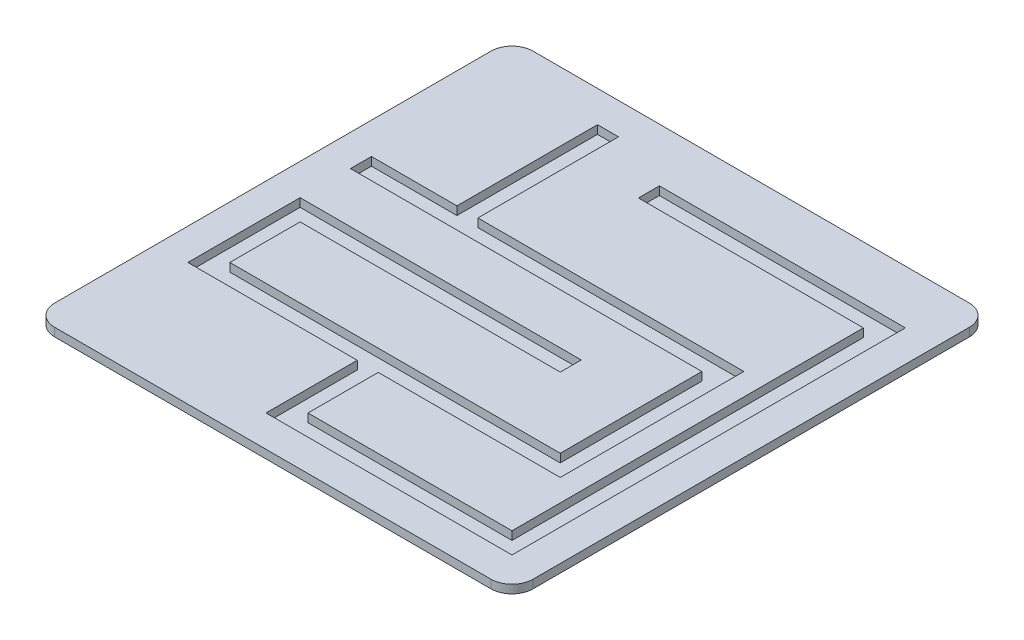
from build123d import *

# Parameters (mm, degrees)
BOSS_EXTRUDE1_DEPTH = 4
CUT_EXTRUDE3_DEPTH  = 12
BOSS_EXTRUDE6_DEPTH = 10


with BuildPart() as part:
    # Sketch1 → Boss-Extrude1 (new body)
    with BuildSketch(Plane(origin=(0, 0, 0), x_dir=(1, 0, 0), z_dir=(0, 1, 0))):
        with BuildLine():
            Line((-104, -114), (104, -114))
            ThreePointArc((104, -114), (111.071067812, -111.071067812), (114, -104))
            Line((114, -104), (114, 104))
            ThreePointArc((114, 104), (111.071067812, 111.071067812), (104, 114))
            Line((104, 114), (-104, 114))
            ThreePointArc((-104, 114), (-111.071067812, 111.071067812), (-114, 104))
            Line((-114, 104), (-114, -104))
            ThreePointArc((-114, -104), (-111.071067812, -111.071067812), (-104, -114))
        make_face()
    extrude(amount=BOSS_EXTRUDE1_DEPTH)

    # Sketch4 → Cut-Extrude3 (cut)
    with BuildSketch(Plane(origin=(0, 0, 0), x_dir=(1, 0, 0), z_dir=(0, 1, 0))):
        Polygon((-58.25, 99), (-58.25, 32), (-99, 32), (-99, 22), (68.5, 22), (68.5, -45.5), (-89, -45.5), (-89, -12), (35, -12), (35, -2), (-99, -2), (-99, -55.5), (-18.25, -55.5), (-18.25, -99), (99, -99), (99, 88.5), (-18.25, 88.5), (-18.25, 78.5), (89, 78.5), (89, -89), (-8.25, -89), (-8.25, -55.5), (78.5, -55.5), (78.5, 32), (-48.25, 32), (-48.25, 99), align=None)
    extrude(amount=CUT_EXTRUDE3_DEPTH, mode=Mode.SUBTRACT)


with BuildPart() as body_2:
    # Sketch4_5 → Boss-Extrude6 (new body)
    with BuildSketch(Plane(origin=(0, 0, 0), x_dir=(1, 0, 0), z_dir=(0, 1, 0))):
        Polygon((-58.25, 99), (-58.25, 32), (-99, 32), (-99, 22), (68.5, 22), (68.5, -45.5), (-89, -45.5), (-89, -12), (35, -12), (35, -2), (-99, -2), (-99, -55.5), (-18.25, -55.5), (-18.25, -99), (99, -99), (99, 88.5), (-18.25, 88.5), (-18.25, 78.5), (89, 78.5), (89, -89), (-8.25, -89), (-8.25, -55.5), (78.5, -55.5), (78.5, 32), (-48.25, 32), (-48.25, 99), align=None)
    extrude(amount=-BOSS_EXTRUDE6_DEPTH)


solid = Compound([part.part, body_2.part])
